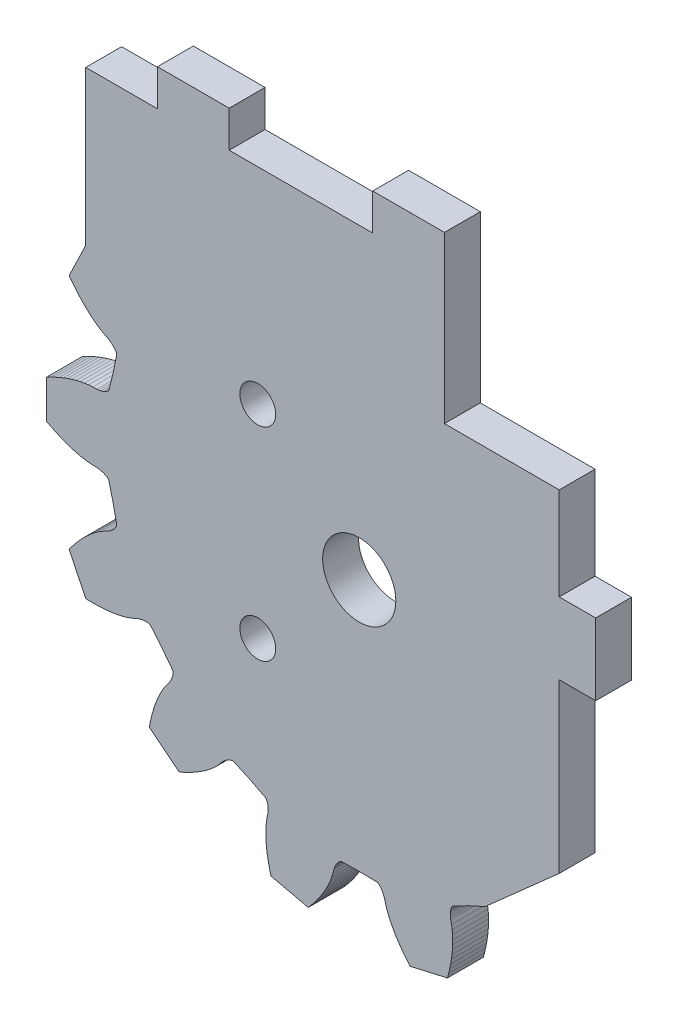
from build123d import *

# Parameters (mm, degrees)
SKETCH1_R                               = 3.2385
BOSS_EXTRUDE1_DEPTH                     = 3.175
BOSS_EXTRUDE2_DEPTH                     = 3.175
SKETCH3_W                               = 29.96848222
SKETCH3_H                               = 58.010526443
CUT_EXTRUDE1_DEPTH                      = 4.175
SKETCH4_W                               = 10.16
SKETCH4_H                               = 11.43
CUT_EXTRUDE2_DEPTH                      = 4.175
SKETCH5_W                               = 6.35
SKETCH5_H                               = 3.2258
SKETCH5_W_2                             = 3.2258
SKETCH5_H_2                             = 6.35
TABS_DEPTH                              = 3.175
SKETCH6_R                               = 1.5875
CUT_FOR_BINDING_SCREWS_DEPTH            = 4.175
CUT_FOR_CLEARANCE_OF_SPACER_SCREW_DEPTH = 4.175


with BuildPart() as part:
    # Sketch1 → Boss-Extrude1 (new body)
    with BuildSketch(Plane.XY):
        Polygon((49.520094, 32.708088), (49.907444, 31.160212), (50.014124, 31.055056), (50.115724, 30.981904), (50.21453, 30.92577), (50.311558, 30.881066), (50.407316, 30.844998), (50.596038, 30.791404), (50.781966, 30.756606), (50.965862, 30.736032), (51.32959, 30.72638), (51.694588, 30.702758), (52.062888, 30.653228), (52.43322, 30.582362), (52.805076, 30.4927), (53.177948, 30.385766), (53.551582, 30.262576), (53.925724, 30.124146), (54.30012, 29.97073), (54.674262, 29.80309), (55.047896, 29.621226), (55.420768, 29.426154), (55.420768, 26.046176), (55.047896, 25.851104), (54.674262, 25.66924), (54.30012, 25.5016), (53.925724, 25.348184), (53.551582, 25.209754), (53.177948, 25.086564), (52.805076, 24.97963), (52.43322, 24.889968), (52.062888, 24.819102), (51.694588, 24.769318), (51.32959, 24.74595), (50.965862, 24.736298), (50.781966, 24.715724), (50.596038, 24.680926), (50.407316, 24.627332), (50.311558, 24.591264), (50.21453, 24.54656), (50.115724, 24.490426), (50.014124, 24.417274), (49.907444, 24.312118), (49.520094, 22.764242), (49.19726, 21.20138), (49.24806, 21.06041), (49.30775, 20.950174), (49.37252, 20.856956), (49.440592, 20.77466), (49.51095, 20.700492), (49.657762, 20.57019), (49.810162, 20.458176), (49.96688, 20.360132), (50.290476, 20.193508), (50.609246, 20.01393), (50.91938, 19.80946), (51.222402, 19.584924), (51.518312, 19.342862), (51.808126, 19.084544), (52.091336, 18.811494), (52.368196, 18.52422), (52.63896, 18.223738), (52.903374, 17.910302), (53.161184, 17.58442), (53.41239, 17.246854), (51.946048, 14.201648), (51.52517, 14.187678), (51.10988, 14.186154), (50.699924, 14.19733), (50.296064, 14.22146), (49.899062, 14.259052), (49.508918, 14.310106), (49.126394, 14.375638), (48.752506, 14.456156), (48.388016, 14.55293), (48.034956, 14.667992), (47.695612, 14.805406), (47.363634, 14.95425), (47.189136, 15.015718), (47.00651, 15.064994), (46.81347, 15.098522), (46.711362, 15.107412), (46.604682, 15.109444), (46.491398, 15.101824), (46.367954, 15.079726), (46.225968, 15.031466), (45.20565, 13.8049), (44.23664, 12.536932), (44.221146, 12.387834), (44.227242, 12.262612), (44.245022, 12.150598), (44.270676, 12.046712), (44.301918, 11.94943), (44.37761, 11.768582), (44.466256, 11.60145), (44.565062, 11.444986), (44.78401, 11.15441), (44.99356, 10.854436), (45.184314, 10.535666), (45.359828, 10.20191), (45.521372, 9.8552), (45.67047, 9.49706), (45.807122, 9.127998), (45.93209, 8.74903), (46.045628, 8.360918), (46.147736, 7.963662), (46.238668, 7.558278), (46.318424, 7.14502), (43.676062, 5.037836), (43.290744, 5.207508), (42.91584, 5.386578), (42.551604, 5.574538), (42.19829, 5.771388), (41.85666, 5.977636), (41.527222, 6.193028), (41.211246, 6.417818), (40.90924, 6.652768), (40.622982, 6.897878), (40.354504, 7.154926), (40.108632, 7.425944), (39.87419, 7.704074), (39.743634, 7.835138), (39.600378, 7.958836), (39.440866, 8.072882), (39.352982, 8.124952), (39.257478, 8.173212), (39.152068, 8.215376), (39.031418, 8.249158), (38.882574, 8.267192), (37.430964, 7.60476), (36.008056, 6.882892), (35.929316, 6.75513), (35.880294, 6.639814), (35.847782, 6.531102), (35.825684, 6.426454), (35.811714, 6.325108), (35.801554, 6.129274), (35.80892, 5.940298), (35.830002, 5.756402), (35.901376, 5.399786), (35.959796, 5.038598), (35.993324, 4.66852), (36.006532, 4.291838), (36.00196, 3.909314), (35.980624, 3.521964), (35.943794, 3.130042), (35.891978, 2.734564), (35.825684, 2.33553), (35.74542, 1.933448), (35.65144, 1.528826), (35.543998, 1.121664), (32.24911, 0.36957), (31.975806, 0.68961), (31.715456, 1.013714), (31.468822, 1.34112), (31.235904, 1.671828), (31.017464, 2.005838), (30.814264, 2.342642), (30.627066, 2.682494), (30.456886, 3.02514), (30.305502, 3.370326), (30.1752, 3.718052), (30.07106, 4.06908), (29.980636, 4.421378), (29.919676, 4.59613), (29.844492, 4.769612), (29.750258, 4.94157), (29.693616, 5.026914), (29.628338, 5.111496), (29.551884, 5.195316), (29.45765, 5.27812), (29.331412, 5.358892), (27.736038, 5.391912), (26.140918, 5.358892), (26.01468, 5.27812), (25.920446, 5.195316), (25.843738, 5.111496), (25.778714, 5.026914), (25.722072, 4.94157), (25.627838, 4.769612), (25.552654, 4.59613), (25.491694, 4.421378), (25.40127, 4.06908), (25.29713, 3.718052), (25.166828, 3.370326), (25.015444, 3.02514), (24.845264, 2.682494), (24.658066, 2.342642), (24.454866, 2.005838), (24.236426, 1.671828), (24.003508, 1.34112), (23.756874, 1.013714), (23.496524, 0.68961), (23.22322, 0.36957), (19.928332, 1.121664), (19.82089, 1.528826), (19.72691, 1.933448), (19.646646, 2.33553), (19.580352, 2.734564), (19.528536, 3.130042), (19.491706, 3.521964), (19.47037, 3.909314), (19.465798, 4.291838), (19.479006, 4.66852), (19.512534, 5.038598), (19.570954, 5.399786), (19.642328, 5.756402), (19.66341, 5.940298), (19.670776, 6.129274), (19.660616, 6.325108), (19.646646, 6.426454), (19.624548, 6.531102), (19.592036, 6.639814), (19.543014, 6.75513), (19.464274, 6.882892), (18.041366, 7.60476), (16.589756, 8.267192), (16.440912, 8.249158), (16.320262, 8.215376), (16.214852, 8.173212), (16.119348, 8.124952), (16.031464, 8.072882), (15.871952, 7.958836), (15.728696, 7.835138), (15.59814, 7.704074), (15.363698, 7.425944), (15.117826, 7.154926), (14.849348, 6.897878), (14.56309, 6.652768), (14.261084, 6.417818), (13.945108, 6.193028), (13.61567, 5.977636), (13.27404, 5.771388), (12.920726, 5.574538), (12.55649, 5.386578), (12.181586, 5.207508), (11.796268, 5.037836), (9.153906, 7.14502), (9.233662, 7.558278), (9.324594, 7.963662), (9.426702, 8.360918), (9.54024, 8.74903), (9.665208, 9.127998), (9.80186, 9.49706), (9.950958, 9.8552), (10.112502, 10.20191), (10.288016, 10.535666), (10.47877, 10.854436), (10.68832, 11.15441), (10.907268, 11.444986), (11.00582, 11.60145), (11.09472, 11.768582), (11.170412, 11.94943), (11.201654, 12.046712), (11.227308, 12.150598), (11.245088, 12.262612), (11.251184, 12.387834), (11.235436, 12.536932), (10.26668, 13.8049), (9.246362, 15.031466), (9.104376, 15.079726), (8.980932, 15.101824), (8.867648, 15.109444), (8.760968, 15.107412), (8.65886, 15.098522), (8.46582, 15.064994), (8.283194, 15.015718), (8.108696, 14.95425), (7.776718, 14.805406), (7.437374, 14.667992), (7.084314, 14.55293), (6.719824, 14.456156), (6.345936, 14.375638), (5.963412, 14.310106), (5.573268, 14.259052), (5.176266, 14.22146), (4.772406, 14.19733), (4.36245, 14.186154), (3.94716, 14.187678), (3.526282, 14.201648), (2.05994, 17.246854), (2.311146, 17.58442), (2.568956, 17.910302), (2.83337, 18.223738), (3.104134, 18.52422), (3.380994, 18.811494), (3.664204, 19.084544), (3.954018, 19.342862), (4.249928, 19.584924), (4.55295, 19.80946), (4.863084, 20.01393), (5.181854, 20.193508), (5.50545, 20.360132), (5.662168, 20.458176), (5.814568, 20.57019), (5.96138, 20.700492), (6.031738, 20.77466), (6.09981, 20.856956), (6.16458, 20.950174), (6.22427, 21.06041), (6.274816, 21.20138), (5.952236, 22.764242), (5.564886, 24.312118), (5.458206, 24.417274), (5.356606, 24.490426), (5.2578, 24.54656), (5.160772, 24.591264), (5.065014, 24.627332), (4.876292, 24.680926), (4.690364, 24.715724), (4.506468, 24.736298), (4.14274, 24.74595), (3.777742, 24.769318), (3.409442, 24.819102), (3.03911, 24.889968), (2.667254, 24.97963), (2.294382, 25.086564), (1.920748, 25.209754), (1.546606, 25.348184), (1.17221, 25.5016), (0.798068, 25.66924), (0.424434, 25.851104), (0.051562, 26.046176), (0.051562, 29.426154), (0.424434, 29.621226), (0.798068, 29.80309), (1.17221, 29.97073), (1.546606, 30.124146), (1.920748, 30.262576), (2.294382, 30.385766), (2.667254, 30.4927), (3.03911, 30.582362), (3.409442, 30.653228), (3.777742, 30.702758), (4.14274, 30.72638), (4.506468, 30.736032), (4.690364, 30.756606), (4.876292, 30.791404), (5.065014, 30.844998), (5.160772, 30.881066), (5.2578, 30.92577), (5.356606, 30.981904), (5.458206, 31.055056), (5.564886, 31.160212), (5.952236, 32.708088), (6.274816, 34.27095), (6.22427, 34.41192), (6.16458, 34.522156), (6.09981, 34.615374), (6.031738, 34.69767), (5.96138, 34.771838), (5.814568, 34.90214), (5.662168, 35.014154), (5.50545, 35.112198), (5.181854, 35.278822), (4.863084, 35.4584), (4.55295, 35.66287), (4.249928, 35.887406), (3.954018, 36.129468), (3.664204, 36.387786), (3.380994, 36.660836), (3.104134, 36.94811), (2.83337, 37.248592), (2.568956, 37.562028), (2.311146, 37.88791), (2.05994, 38.225476), (3.526282, 41.270682), (3.94716, 41.284652), (4.36245, 41.286176), (4.772406, 41.275), (5.176266, 41.25087), (5.573268, 41.213278), (5.963412, 41.162224), (6.345936, 41.096692), (6.719824, 41.016174), (7.084314, 40.9194), (7.437374, 40.804338), (7.776718, 40.666924), (8.108696, 40.51808), (8.283194, 40.456612), (8.46582, 40.407336), (8.65886, 40.373808), (8.760968, 40.364918), (8.867648, 40.362886), (8.980932, 40.370506), (9.104376, 40.392604), (9.246362, 40.440864), (10.26668, 41.66743), (11.235436, 42.935398), (11.251184, 43.084496), (11.245088, 43.209718), (11.227308, 43.321732), (11.201654, 43.425618), (11.170412, 43.5229), (11.09472, 43.703748), (11.00582, 43.87088), (10.907268, 44.027344), (10.68832, 44.31792), (10.47877, 44.617894), (10.288016, 44.936664), (10.112502, 45.27042), (9.950958, 45.61713), (9.80186, 45.97527), (9.665208, 46.344332), (9.54024, 46.7233), (9.426702, 47.111412), (9.324594, 47.508668), (9.233662, 47.914052), (9.153906, 48.32731), (11.796268, 50.434494), (12.181586, 50.264822), (12.55649, 50.085752), (12.920726, 49.897792), (13.27404, 49.700942), (13.61567, 49.494694), (13.945108, 49.279302), (14.261084, 49.054512), (14.56309, 48.819562), (14.849348, 48.574452), (15.117826, 48.317404), (15.363698, 48.046386), (15.59814, 47.768256), (15.728696, 47.637192), (15.871952, 47.513494), (16.031464, 47.399448), (16.119348, 47.347124), (16.214852, 47.299118), (16.320262, 47.256954), (16.440912, 47.223172), (16.589756, 47.205138), (18.041366, 47.86757), (19.464274, 48.589438), (19.543014, 48.7172), (19.592036, 48.832516), (19.624548, 48.941228), (19.646646, 49.045876), (19.660616, 49.147222), (19.670776, 49.343056), (19.66341, 49.532032), (19.642328, 49.715928), (19.570954, 50.072544), (19.512534, 50.433732), (19.479006, 50.80381), (19.465798, 51.180492), (19.47037, 51.563016), (19.491706, 51.950366), (19.528536, 52.342288), (19.580352, 52.737766), (19.82089, 52.737766), (20.372537713, 53.129688), (21.034433175, 53.466492), (21.492668494, 53.800502), (22.358224098, 54.13121), (23.22322, 54.13121), (23.756874, 54.13121), (24.003508, 54.13121), (24.236426, 53.800502), (24.454866, 53.466492), (24.658066, 53.129688), (24.845264, 52.789836), (25.015444, 52.44719), (25.166828, 52.102004), (25.29713, 51.754024), (25.40127, 51.40325), (25.491694, 51.050952), (25.552654, 50.8762), (25.627838, 50.702718), (25.722072, 50.53076), (25.778714, 50.445416), (25.843738, 50.360834), (25.920446, 50.277014), (26.01468, 50.19421), (26.140918, 50.113438), (27.736038, 50.080418), (29.331412, 50.113438), (29.45765, 50.19421), (29.551884, 50.277014), (29.628338, 50.360834), (29.693616, 50.445416), (29.750258, 50.53076), (29.844492, 50.702718), (29.919676, 50.8762), (29.980636, 51.050952), (30.07106, 51.40325), (30.1752, 51.754024), (30.305502, 52.102004), (30.456886, 52.44719), (30.627066, 52.789836), (30.814264, 53.129688), (31.017464, 53.466492), (31.235904, 53.800502), (31.468822, 54.13121), (31.975806, 53.800502), (32.795806377, 53.800502), (33.763192052, 53.800502), (34.628747656, 53.800502), (35.443388224, 53.61078489), (35.74542, 53.538882), (35.825684, 53.1368), (35.891978, 52.737766), (35.943794, 52.342288), (35.980624, 51.950366), (36.00196, 51.563016), (36.006532, 51.180492), (35.993324, 50.80381), (35.959796, 50.433732), (35.901376, 50.072544), (35.830002, 49.715928), (35.80892, 49.532032), (35.801554, 49.343056), (35.811714, 49.147222), (35.825684, 49.045876), (35.847782, 48.941228), (35.880294, 48.832516), (35.929316, 48.7172), (36.008056, 48.589438), (37.430964, 47.86757), (38.882574, 47.205138), (39.031418, 47.223172), (39.152068, 47.256954), (39.257478, 47.299118), (39.352982, 47.347124), (39.440866, 47.399448), (39.600378, 47.513494), (39.743634, 47.637192), (39.87419, 47.768256), (40.108632, 48.046386), (40.354504, 48.317404), (40.622982, 48.574452), (40.90924, 48.819562), (41.211246, 49.054512), (41.527222, 49.279302), (41.85666, 49.494694), (42.19829, 49.700942), (42.551604, 49.897792), (42.91584, 50.085752), (43.290744, 50.264822), (43.676062, 50.434494), (46.318424, 48.32731), (46.238668, 47.914052), (46.147736, 47.508668), (46.045628, 47.111412), (45.93209, 46.7233), (45.807122, 46.344332), (45.67047, 45.97527), (45.521372, 45.61713), (45.359828, 45.27042), (45.184314, 44.936664), (44.99356, 44.617894), (44.78401, 44.31792), (44.565062, 44.027344), (44.466256, 43.87088), (44.37761, 43.703748), (44.301918, 43.5229), (44.270676, 43.425618), (44.245022, 43.321732), (44.227242, 43.209718), (44.221146, 43.084496), (44.23664, 42.935398), (45.20565, 41.66743), (46.225968, 40.440864), (46.367954, 40.392604), (46.491398, 40.370506), (46.604682, 40.362886), (46.711362, 40.364918), (46.81347, 40.373808), (47.00651, 40.407336), (47.189136, 40.456612), (47.363634, 40.51808), (47.695612, 40.666924), (48.034956, 40.804338), (48.388016, 40.9194), (48.752506, 41.016174), (49.126394, 41.096692), (49.508918, 41.162224), (49.899062, 41.213278), (50.296064, 41.25087), (50.699924, 41.275), (51.10988, 41.286176), (51.52517, 41.284652), (51.946048, 41.270682), (53.41239, 38.225476), (53.161184, 37.88791), (52.903374, 37.562028), (52.63896, 37.248592), (52.368196, 36.94811), (52.091336, 36.660836), (51.808126, 36.387786), (51.518312, 36.129468), (51.222402, 35.887406), (50.91938, 35.66287), (50.609246, 35.4584), (50.290476, 35.278822), (49.96688, 35.112198), (49.810162, 35.014154), (49.657762, 34.90214), (49.51095, 34.771838), (49.440592, 34.69767), (49.37252, 34.615374), (49.30775, 34.522156), (49.24806, 34.41192), (49.19726, 34.27095), align=None)
        with Locations((27.736038, 27.736038)):
            Circle(SKETCH1_R, mode=Mode.SUBTRACT)
    extrude(amount=BOSS_EXTRUDE1_DEPTH)

    # Sketch2 → Boss-Extrude2 (add)
    with BuildSketch(Plane.XY.offset(3.175)):
        Polygon((3.526282, 41.270682), (3.526282, 54.914038), (46.225968, 54.914038), (46.225968, 15.031466), (34.609948438, 32.843973929), (21.58017356, 32.843973929), align=None)
    extrude(amount=-BOSS_EXTRUDE2_DEPTH)

    # Sketch3 → Cut-Extrude1 (cut, through all)
    with BuildSketch(Plane.XY.offset(3.175)):
        with Locations((60.42052311, 25.908774779)):
            Rectangle(SKETCH3_W, SKETCH3_H)
    extrude(amount=-CUT_EXTRUDE1_DEPTH, mode=Mode.SUBTRACT)

    # Sketch4 → Cut-Extrude2 (cut, through all)
    with BuildSketch(Plane.XY.offset(3.175)):
        with Locations((40.356282, 49.199038)):
            Rectangle(SKETCH4_W, SKETCH4_H)
    extrude(amount=-CUT_EXTRUDE2_DEPTH, mode=Mode.SUBTRACT)

    # Sketch5 → tabs (add)
    with BuildSketch(Plane.XY.offset(3.175)):
        with Locations((13.051282, 56.526938)):
            Rectangle(SKETCH5_W, SKETCH5_H)
        with Locations((32.101282, 56.526938)):
            Rectangle(SKETCH5_W, SKETCH5_H)
        with Locations((47.049182, 32.103866967)):
            Rectangle(SKETCH5_W_2, SKETCH5_H_2)
    extrude(amount=-TABS_DEPTH)

    # Sketch6 → cut for binding screws (cut, through all)
    with BuildSketch(Plane.XY.offset(3.175)):
        with Locations((18.755781879, 36.716294121)):
            Circle(SKETCH6_R)
        with Locations((18.755781879, 18.755781879)):
            Circle(SKETCH6_R)
    extrude(amount=-CUT_FOR_BINDING_SCREWS_DEPTH, mode=Mode.SUBTRACT)

    # Sketch7 → cut for clearance of spacer screw (cut, through all)
    with BuildSketch(Plane.XY.offset(3.175)):
        Polygon((45.436282, 14.08215216), (38.882574, 8.267192), (39.152068, -1.013026628), (51.147316922, -1.013026628), (51.147316922, 14.08215216), align=None)
    extrude(amount=-CUT_FOR_CLEARANCE_OF_SPACER_SCREW_DEPTH, mode=Mode.SUBTRACT)


solid = part.part
